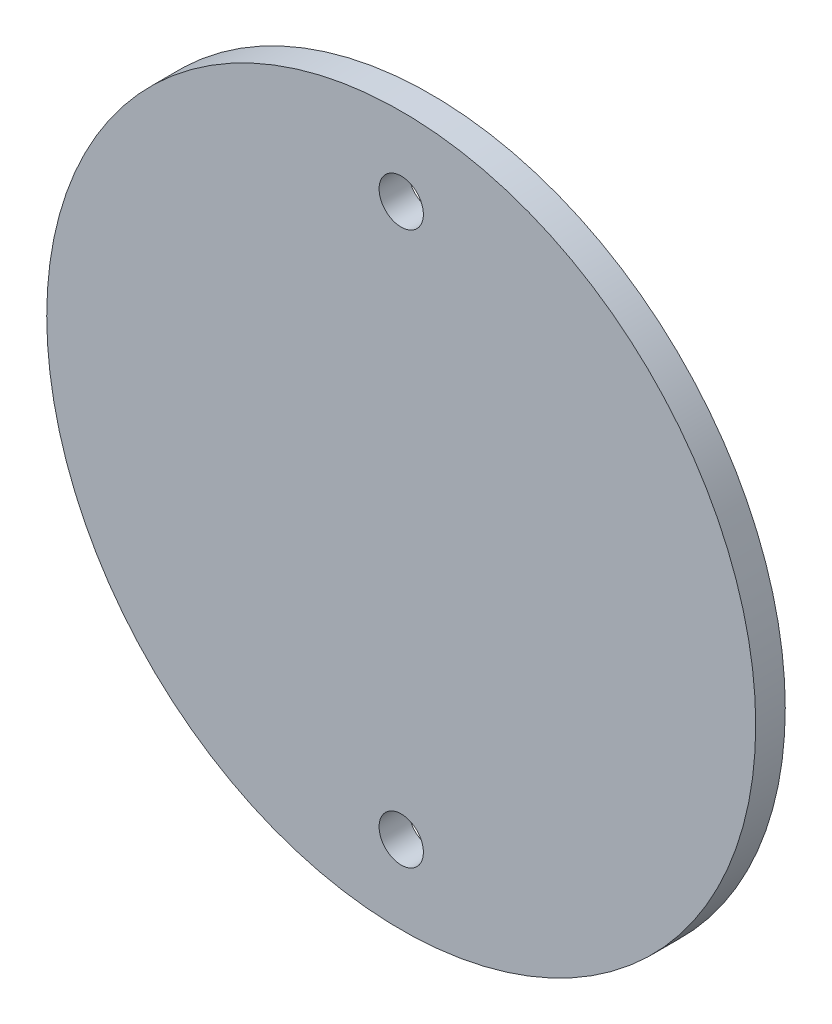
from build123d import *

# Parameters (mm, degrees)
SKETCH1_R           = 76.2
SKETCH1_R_2         = 4.7625
BOSS_EXTRUDE1_DEPTH = 6.35


with BuildPart() as part:
    # Sketch1 → Boss-Extrude1 (new body)
    with BuildSketch(Plane.XY):
        Circle(SKETCH1_R)
        with Locations((0, 59.3725)):
            Circle(SKETCH1_R_2, mode=Mode.SUBTRACT)
        with Locations((0, -59.3725)):
            Circle(SKETCH1_R_2, mode=Mode.SUBTRACT)
    extrude(amount=BOSS_EXTRUDE1_DEPTH)


solid = part.part
